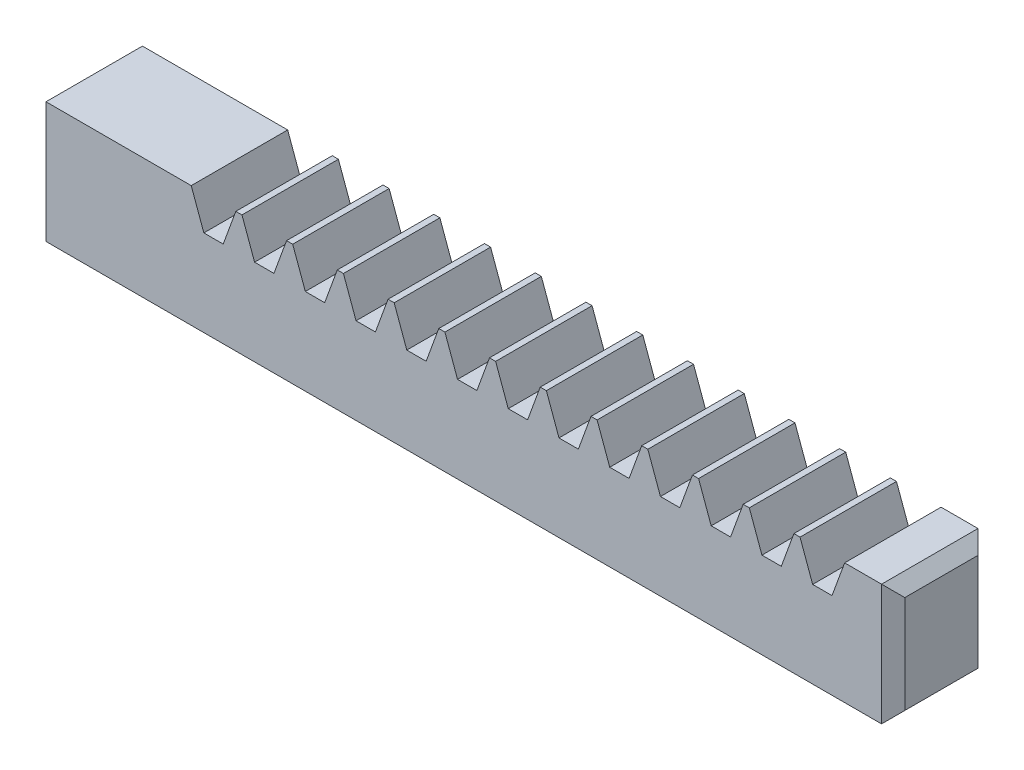
from build123d import *

# Parameters (mm, degrees)
SKETCH1_W           = 12.6492
SKETCH1_H           = 15.875
BOSS_EXTRUDE1_DEPTH = 111.125
HOLE1_D             = 6.35
HOLE1_DEPTH         = 15.875
CUT_EXTRUDE1_START  = -13.6492
CUT_EXTRUDE1_DEPTH  = 14.6492
LPATTERN2_COUNT     = 13
LPATTERN2_PITCH     = 6.6548
CHAMFER1_SIZE       = 1.524


with BuildPart() as part:
    # Sketch1 → Boss-Extrude1 (new body)
    with BuildSketch(Plane(origin=(0, 0, 0), x_dir=(0, 0, -1), z_dir=(1, 0, 0))):
        Rectangle(SKETCH1_W, SKETCH1_H)
    extrude(amount=BOSS_EXTRUDE1_DEPTH)

    # Hole1
    with Locations(Plane.ZY):
        with Locations((0, 0)):
            Hole(HOLE1_D / 2, depth=HOLE1_DEPTH)

    # Sketch4 → Cut-Extrude1 (cut)
    with BuildSketch(Plane.XY.offset(6.3246).offset(CUT_EXTRUDE1_START)):
        Polygon((-48.282488077, 192.931990587), (19.05, 7.9375), (20.704827067, 3.3909), (23.244827067, 3.3909), (24.899654134, 7.9375), (92.232142211, 192.931990587), (92.232142211, 586.666040414), (-48.282488077, 586.666040414), align=None)
    cut_extrude1 = extrude(amount=CUT_EXTRUDE1_DEPTH, mode=Mode.SUBTRACT)

    # LPattern2: Cut-Extrude1 ×13
    with Locations(*[(i * LPATTERN2_PITCH, 0, 0) for i in range(1, LPATTERN2_COUNT)]):
        add(cut_extrude1, mode=Mode.SUBTRACT)

    # Chamfer1
    chamfer1_edges = [part.edges().sort_by_distance(p)[0] for p in [
        (111.125, 0, 6.3246),
        (111.125, -7.9375, 0),
        (111.125, 0, -6.3246),
        (111.125, 7.9375, 0),
    ]]
    chamfer(chamfer1_edges, length=CHAMFER1_SIZE)


solid = part.part
